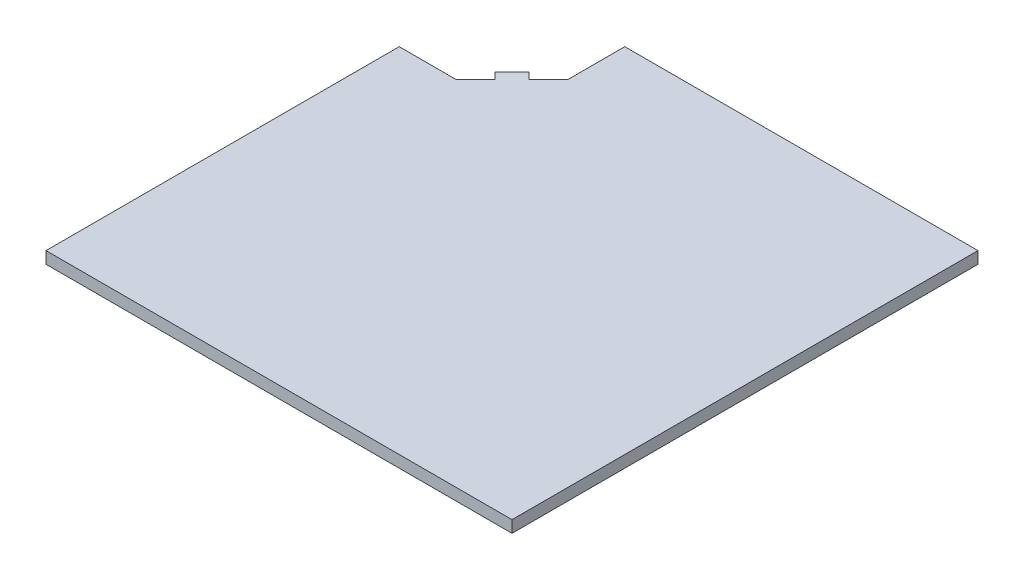
from build123d import *

# Parameters (mm, degrees)
SKETCH1_W           = 7.85
SKETCH1_H           = 7.85
BOSS_EXTRUDE1_DEPTH = 0.2
CUT_EXTRUDE1_DEPTH  = 1.2


with BuildPart() as part:
    # Sketch1 → Boss-Extrude1 (new body)
    with BuildSketch(Plane(origin=(0, 0, 0), x_dir=(1, 0, 0), z_dir=(0, 1, 0))):
        Rectangle(SKETCH1_W, SKETCH1_H)
    extrude(amount=BOSS_EXTRUDE1_DEPTH)

    # Sketch3 → Cut-Extrude1 (cut, through all)
    with BuildSketch(Plane(origin=(0, 0.2, 0), x_dir=(1, 0, 0), z_dir=(0, 1, 0))):
        Polygon((-3.925, 2.025), (-2.97297934, 2.025), (-2.640411026, 2.357568314), (-2.746477043, 2.463634331), (-2.463634331, 2.746477043), (-2.357568314, 2.640411026), (-2.025, 2.97297934), (-2.025, 3.925), (-3.925, 3.925), align=None)
    extrude(amount=-CUT_EXTRUDE1_DEPTH, mode=Mode.SUBTRACT)


solid = part.part
